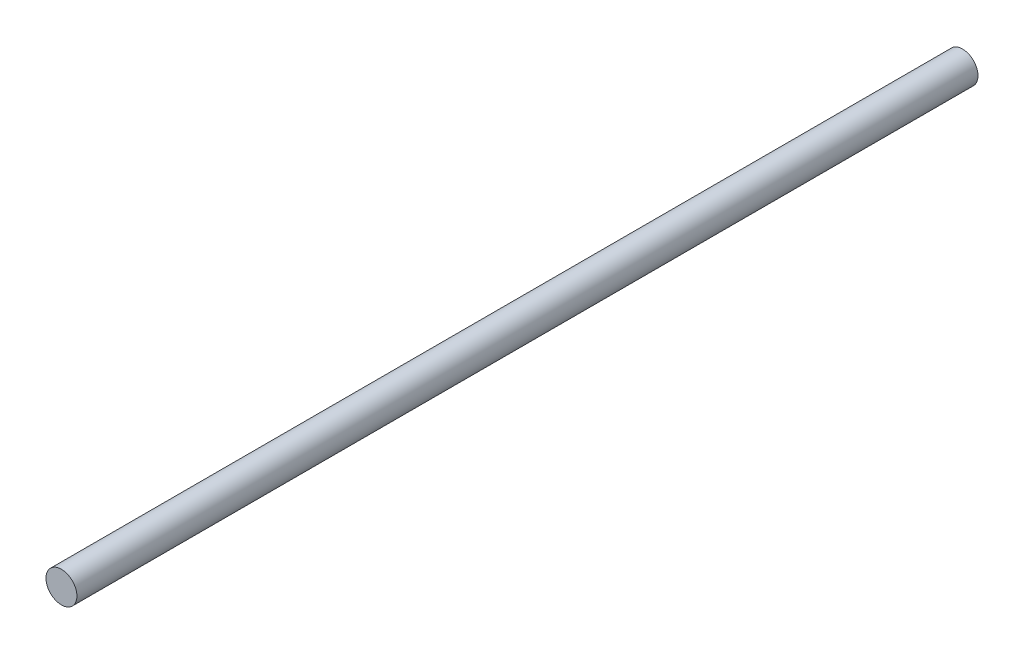
from build123d import *

# Parameters (mm, degrees)
CROQUIS1_R              = 3.5
SALIENTE_EXTRUIR1_DEPTH = 204


with BuildPart() as part:
    # Croquis1 → Saliente-Extruir1 (new body)
    with BuildSketch(Plane.XY):
        Circle(CROQUIS1_R)
    extrude(amount=SALIENTE_EXTRUIR1_DEPTH)


solid = part.part
